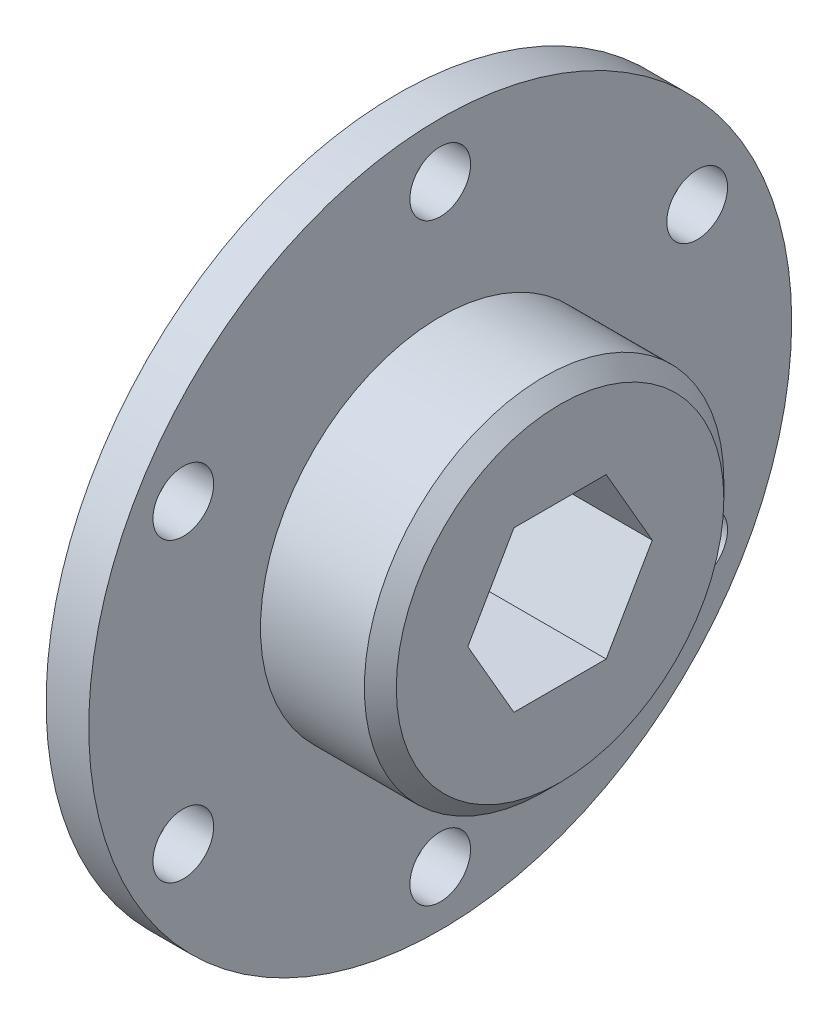
from build123d import *

# Parameters (mm, degrees)
SKETCH1_R           = 27.94
SKETCH1_R_2         = 2.413
BOSS_EXTRUDE1_DEPTH = 3.3909
SKETCH2_R           = 14.2875
BOSS_EXTRUDE2_DEPTH = 9.525
CHAMFER1_SIZE       = 1.27


with BuildPart() as part:
    # Sketch1 → Boss-Extrude1 (new body)
    with BuildSketch(Plane(origin=(0, 0, 0), x_dir=(0, 0, -1), z_dir=(1, 0, 0))):
        Circle(SKETCH1_R)
        with Locations((0, 23.5839)):
            Circle(SKETCH1_R_2, mode=Mode.SUBTRACT)
        with Locations((20.42425652, 11.79195)):
            Circle(SKETCH1_R_2, mode=Mode.SUBTRACT)
        with Locations((20.42425652, -11.79195)):
            Circle(SKETCH1_R_2, mode=Mode.SUBTRACT)
        with Locations((0, -23.5839)):
            Circle(SKETCH1_R_2, mode=Mode.SUBTRACT)
        with Locations((-20.42425652, -11.79195)):
            Circle(SKETCH1_R_2, mode=Mode.SUBTRACT)
        with Locations((-20.42425652, 11.79195)):
            Circle(SKETCH1_R_2, mode=Mode.SUBTRACT)
        Polygon((7.332348419, 0), (3.666174209, 6.35), (-3.666174209, 6.35), (-7.332348419, 0), (-3.666174209, -6.35), (3.666174209, -6.35), align=None, mode=Mode.SUBTRACT)
    extrude(amount=BOSS_EXTRUDE1_DEPTH)

    # Sketch2 → Boss-Extrude2 (add)
    with BuildSketch(Plane(origin=(3.3909, 0, 0), x_dir=(0, 0, -1), z_dir=(1, 0, 0))):
        Circle(SKETCH2_R)
        Polygon((3.666174209, -6.35), (7.332348419, 0), (3.666174209, 6.35), (-3.666174209, 6.35), (-7.332348419, 0), (-3.666174209, -6.35), align=None, mode=Mode.SUBTRACT)
    extrude(amount=BOSS_EXTRUDE2_DEPTH)

    # Chamfer1
    chamfer1_edges = [part.edges().sort_by_distance(p)[0] for p in [
        (12.9159, 0, 14.2875),
    ]]
    chamfer(chamfer1_edges, length=CHAMFER1_SIZE)


solid = part.part
